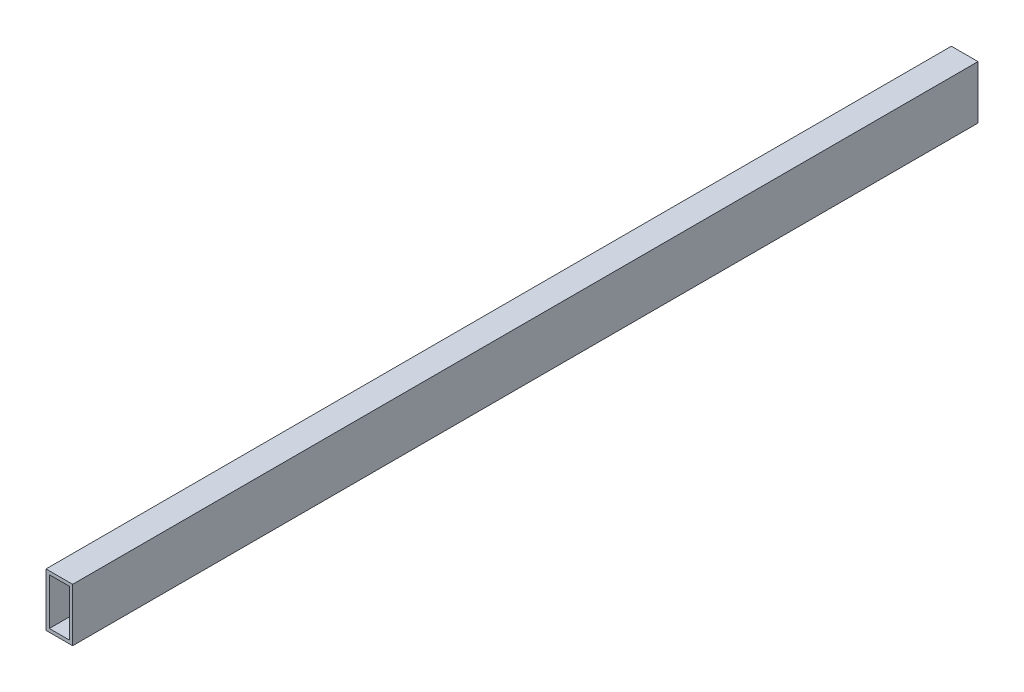
from build123d import *

# Parameters (mm, degrees)
SKETCH1_W           = 12.7
SKETCH1_H           = 25.4
SKETCH1_W_2         = 9.525
SKETCH1_H_2         = 22.225
BOSS_EXTRUDE1_DEPTH = 431.8


with BuildPart() as part:
    # Sketch1 → Boss-Extrude1 (new body)
    with BuildSketch(Plane.XY):
        with Locations((6.35, 12.7)):
            Rectangle(SKETCH1_W, SKETCH1_H)
        with Locations((6.35, 12.7)):
            Rectangle(SKETCH1_W_2, SKETCH1_H_2, mode=Mode.SUBTRACT)
    extrude(amount=BOSS_EXTRUDE1_DEPTH)


solid = part.part
